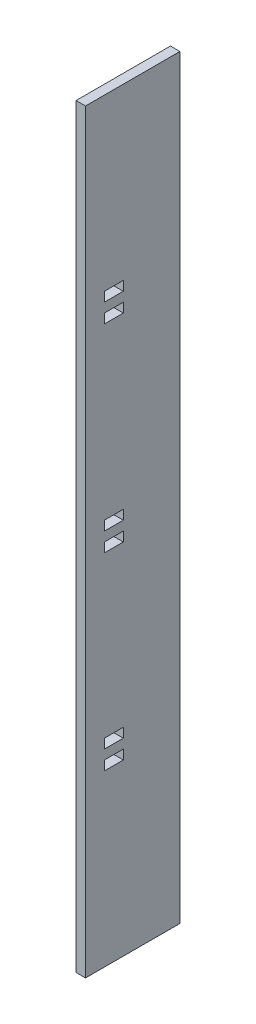
from build123d import *

# Parameters (mm, degrees)
SKETCH2_W           = 63.5
SKETCH2_H           = 508
SKETCH2_W_2         = 12.7
SKETCH2_H_2         = 6.35
BOSS_EXTRUDE1_DEPTH = 6.35


with BuildPart() as part:
    # Sketch2 → Boss-Extrude1 (new body)
    with BuildSketch(Plane(origin=(0, 0, 0), x_dir=(0, 0, -1), z_dir=(1, 0, 0))):
        with Locations((31.75, 254)):
            Rectangle(SKETCH2_W, SKETCH2_H)
        with Locations((19.05, 390.525)):
            Rectangle(SKETCH2_W_2, SKETCH2_H_2, mode=Mode.SUBTRACT)
        with Locations((19.05, 130.175)):
            Rectangle(SKETCH2_W_2, SKETCH2_H_2, mode=Mode.SUBTRACT)
        with Locations((19.05, 257.175)):
            Rectangle(SKETCH2_W_2, SKETCH2_H_2, mode=Mode.SUBTRACT)
        with Locations((19.05, 117.475)):
            Rectangle(SKETCH2_W_2, SKETCH2_H_2, mode=Mode.SUBTRACT)
        with Locations((19.05, 244.475)):
            Rectangle(SKETCH2_W_2, SKETCH2_H_2, mode=Mode.SUBTRACT)
        with Locations((19.05, 377.825)):
            Rectangle(SKETCH2_W_2, SKETCH2_H_2, mode=Mode.SUBTRACT)
    extrude(amount=BOSS_EXTRUDE1_DEPTH)


solid = part.part
